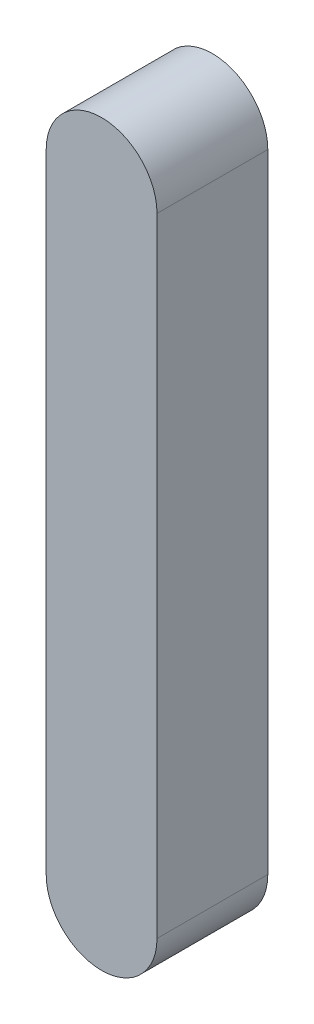
from build123d import *

# Parameters (mm, degrees)
BOSS_EXTRUDE1_DEPTH = 6


with BuildPart() as part:
    # Sketch1 → Boss-Extrude1 (new body)
    with BuildSketch(Plane.XY):
        with BuildLine():
            Line((74.200156848, 56.899891413), (74.200156848, 22.899891413))
            ThreePointArc((74.200156848, 22.899891413), (77.200156848, 19.899891413), (80.200156848, 22.899891413))
            Line((80.200156848, 22.899891413), (80.200156848, 56.899891413))
            ThreePointArc((80.200156848, 56.899891413), (77.200156848, 59.899891413), (74.200156848, 56.899891413))
        make_face()
    extrude(amount=BOSS_EXTRUDE1_DEPTH)


solid = part.part
